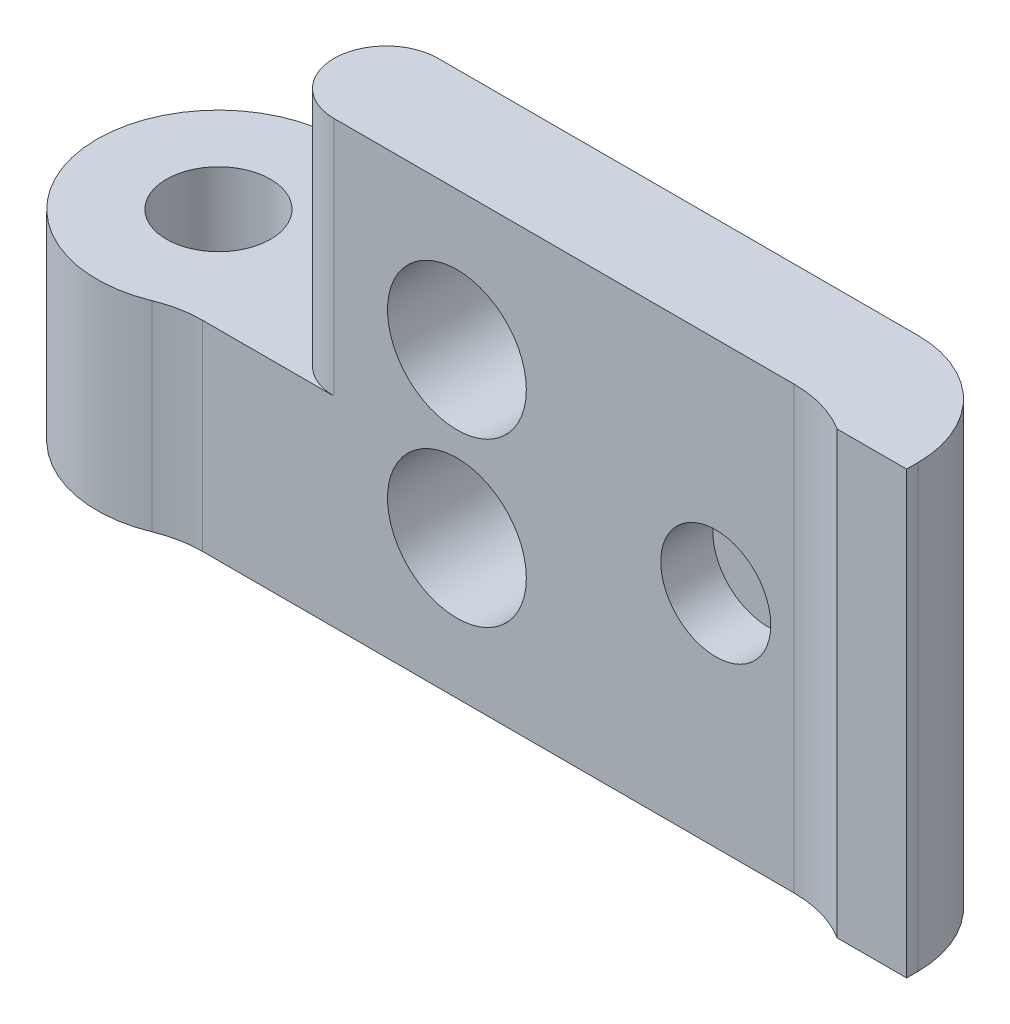
from build123d import *

# Parameters (mm, degrees)
SKETCH1_R           = 3.5
BOSS_EXTRUDE1_DEPTH = 12.7
CUT_EXTRUDE1_DEPTH  = 6.93
SKETCH3_R           = 1.5
CUT_EXTRUDE2_DEPTH  = 6.77
SKETCH4_R           = 2
CUT_EXTRUDE3_DEPTH  = 10
SKETCH5_W           = 2
SKETCH5_H           = 0.5
BOSS_EXTRUDE2_DEPTH = 12.7
FILLET1_R           = 3.175
SKETCH6_R           = 1.585
CUT_EXTRUDE4_DEPTH  = 1.5


with BuildPart() as part:
    # Sketch1 → Boss-Extrude1 (new body)
    with BuildSketch(Plane(origin=(0, 0, 0), x_dir=(1, 0, 0), z_dir=(0, 1, 0))):
        Circle(SKETCH1_R)
        with BuildLine():
            ThreePointArc((1.802775638, 3), (3.046285831, 1.723410176), (3.5, 0))
            Line((3.5, 0), (23.330212793, 0))
            Line((23.330212793, 0), (23.330212793, 3))
            Line((23.330212793, 3), (1.802775638, 3))
        make_face()
    extrude(amount=BOSS_EXTRUDE1_DEPTH)

    # Sketch2 → Cut-Extrude1 (cut)
    with BuildSketch(Plane(origin=(0, 12.7, 0), x_dir=(1, 0, 0), z_dir=(0, 1, 0))):
        with BuildLine():
            ThreePointArc((6.330212793, 3), (-6.149926342, 1.5), (6.330212793, 0))
            Line((6.330212793, 0), (3.5, 0))
            ThreePointArc((3.5, 0), (-3.046285831, -1.723410176), (1.802775638, 3))
            Line((1.802775638, 3), (6.330212793, 3))
        make_face()
        with BuildLine():
            Line((3.5, 0), (6.330212793, 0))
            ThreePointArc((6.330212793, 0), (4.830212793, 1.5), (6.330212793, 3))
            Line((6.330212793, 3), (1.802775638, 3))
            ThreePointArc((1.802775638, 3), (-3.046285831, -1.723410176), (3.5, 0))
        make_face()
    extrude(amount=-CUT_EXTRUDE1_DEPTH, mode=Mode.SUBTRACT)

    # Sketch3 → Cut-Extrude2 (cut, through all)
    with BuildSketch(Plane(origin=(0, 5.77, 0), x_dir=(1, 0, 0), z_dir=(0, 1, 0))):
        with Locations(Location((0, 0, 0), (0, 0, 270))):  # turned: the seam where the file's is
            Circle(SKETCH3_R)
    extrude(amount=-CUT_EXTRUDE2_DEPTH, mode=Mode.SUBTRACT)


with BuildPart() as body_2:
    # Mirror1: mirrored copy
    add(part.part.mirror(Plane.XY.offset(-5)))

    # Sketch4 → Cut-Extrude3 (cut)
    with BuildSketch(Plane.XY.offset(-7)):
        with Locations((9.871541535, 8.7)):
            Circle(SKETCH4_R)
        with Locations((9.871541535, 4)):
            Circle(SKETCH4_R)
    extrude(amount=-CUT_EXTRUDE3_DEPTH, mode=Mode.SUBTRACT)

    # Sketch5 → Boss-Extrude2 (add)
    with BuildSketch(Plane(origin=(0, 12.7, 0), x_dir=(1, 0, 0), z_dir=(0, 1, 0))):
        with BuildLine():
            Line((21.330212793, 6.5), (21.330212793, 7))
            Line((21.330212793, 7), (19.59096008, 7))
            ThreePointArc((19.59096008, 7), (20.495808134, 6.872518864), (21.330212793, 6.5))
        make_face()
        with Locations((22.330212793, 6.75)):
            Rectangle(SKETCH5_W, SKETCH5_H)
    extrude(amount=-BOSS_EXTRUDE2_DEPTH)

    # Fillet1
    fillet1_edges = [body_2.edges().sort_by_distance(p)[0] for p in [
        (1.802775638, 2.885, -7),
        (3.5, 2.885, -10),
        (23.330212793, 6.35, -10),
    ]]
    fillet(fillet1_edges, radius=FILLET1_R)

    # Sketch6 → Cut-Extrude4 (cut)
    with BuildSketch(Plane.XY.offset(-7)):
        with Locations((17.330212793, 6.35)):
            Circle(SKETCH6_R)
    extrude(amount=-CUT_EXTRUDE4_DEPTH, mode=Mode.SUBTRACT)


solid = body_2.part
